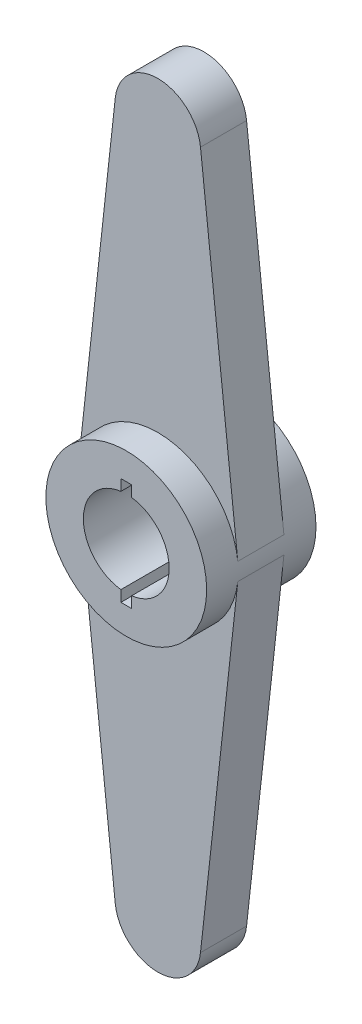
from build123d import *

# Parameters (mm, degrees)
BOSS_EXTRUDE1_DEPTH = 2.55
BOSS_EXTRUDE2_DEPTH = 1.075


with BuildPart() as part:
    # Sketch1 → Boss-Extrude1 (new body, symmetric)
    with BuildSketch(Plane.XY):
        with BuildLine():
            ThreePointArc((3.727642468, 0.408878505), (0, 3.75), (-3.727642468, 0.408878505))
            ThreePointArc((-3.727642468, 0.408878505), (-3.75, 0), (-3.727642468, -0.408878505))
            ThreePointArc((-3.727642468, -0.408878505), (0, -3.75), (3.727642468, -0.408878505))
            ThreePointArc((3.727642468, -0.408878505), (3.744406445, -0.204744652), (3.75, 0))
            ThreePointArc((3.75, 0), (3.744406445, 0.204744652), (3.727642468, 0.408878505))
        make_face()
        with BuildLine():
            Line((0.25, -1.984313483), (0.25, -2.5))
            Line((0.25, -2.5), (-0.25, -2.5))
            Line((-0.25, -2.5), (-0.25, -1.984313483))
            ThreePointArc((-0.25, -1.984313483), (-2, 0), (-0.25, 1.984313483))
            Line((-0.25, 1.984313483), (-0.25, 2.5))
            Line((-0.25, 2.5), (0.25, 2.5))
            Line((0.25, 2.5), (0.25, 1.984313483))
            ThreePointArc((0.25, 1.984313483), (1.5, 1.322875656), (2, 0))
            ThreePointArc((2, 0), (1.5, -1.322875656), (0.25, -1.984313483))
        make_face(mode=Mode.SUBTRACT)
    extrude(amount=BOSS_EXTRUDE1_DEPTH, both=True)

    # Sketch2 → Boss-Extrude2 (add, symmetric)
    with BuildSketch(Plane.XY):
        with BuildLine():
            Line((-1.988075983, 16.268068536), (-3.727642468, 0.408878505))
            ThreePointArc((-3.727642468, 0.408878505), (0, 3.75), (3.727642468, 0.408878505))
            Line((3.727642468, 0.408878505), (1.988075983, 16.268068536))
            ThreePointArc((1.988075983, 16.268068536), (0, 18.05), (-1.988075983, 16.268068536))
        make_face()
        with BuildLine():
            ThreePointArc((3.727642468, -0.408878505), (0, -3.75), (-3.727642468, -0.408878505))
            Line((-3.727642468, -0.408878505), (-1.988075983, -16.268068536))
            ThreePointArc((-1.988075983, -16.268068536), (0, -18.05), (1.988075983, -16.268068536))
            Line((1.988075983, -16.268068536), (3.727642468, -0.408878505))
        make_face()
    extrude(amount=BOSS_EXTRUDE2_DEPTH, both=True)


solid = part.part
